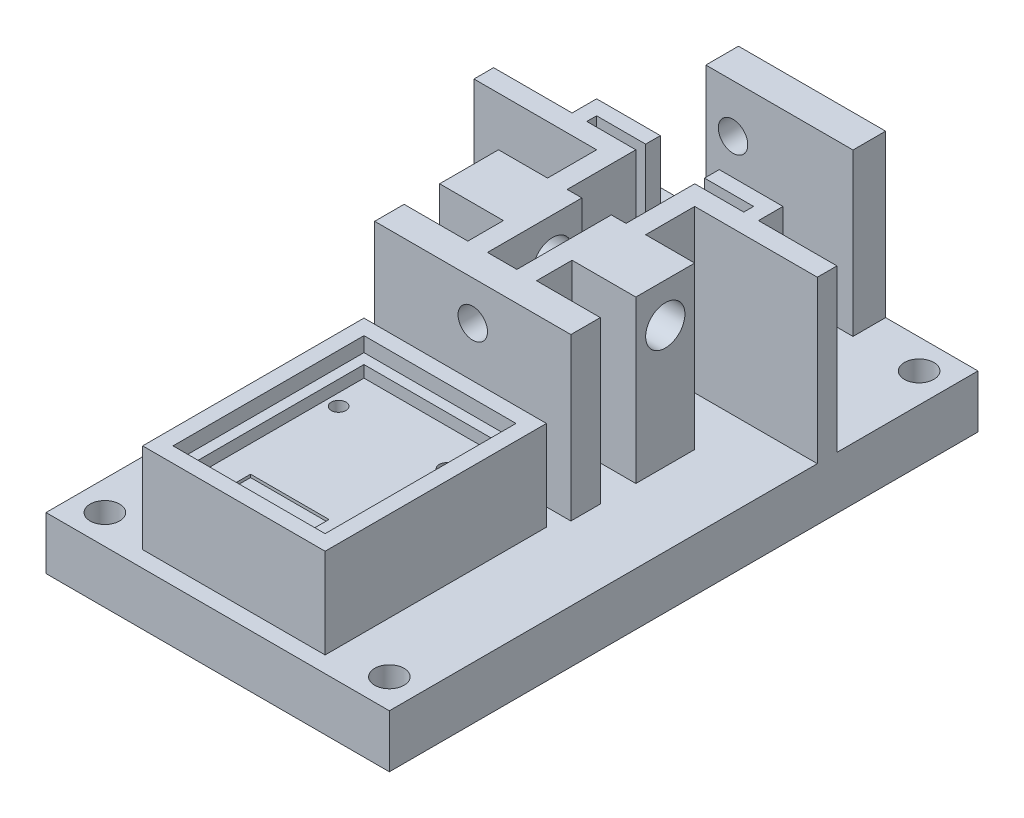
from build123d import *

# Parameters (mm, degrees)
SKETCH1_W                      = 35
SKETCH1_H                      = 60
FLATBASE_DEPTH                 = 5.39
SKETCH19_R                     = 1.5
FLATBASEHOLES_DEPTH            = 6.39
SKETCH2_W                      = 20
SKETCH2_H                      = 3
FILAMENT_LASER_INTERFACE_DEPTH = 16.46
SKETCH4_R                      = 1.5
LASERHOLE_DEPTH                = 3
SKETCH8_W                      = 18.6
SKETCH8_H                      = 22.56
LASER_BASE_DEPTH               = 7.66
SKETCH9_W                      = 13.4
SKETCH9_H                      = 17.36
LASERBOARDMAINCUT_DEPTH        = 1.2
SKETCH11_W                     = 8
SKETCH11_H                     = 4
LASERBOARD_PINHPLES_DEPTH      = 1.5
SKETCH13_W                     = 18.6
SKETCH13_H                     = 22.56
SKETCH13_W_2                   = 15.5
SKETCH13_H_2                   = 19.46
LASERBOARD_SKIRTING_DEPTH      = 1.5
SKETCH14_R                     = 0.75
LASERBOARD_SCREWHOLES_DEPTH    = 12.85
SKETCH20_W                     = 20
SKETCH20_H                     = 6
BOSS_EXTRUDE1_DEPTH            = 16.46
SKETCH22_R                     = 1.115
CUT_EXTRUDE1_DEPTH             = 20
SKETCH23_W                     = 3
SKETCH23_H                     = 6
CUT_EXTRUDE2_DEPTH             = 10
SKETCH24_R                     = 2
CUT_EXTRUDE3_DEPTH             = 4
SKETCH25_R                     = 2
CUT_EXTRUDE4_DEPTH             = 4
SKETCH26_W                     = 2
SKETCH26_H                     = 3.623584384
BOSS_EXTRUDE2_DEPTH            = 16.46
SKETCH27_W                     = 15
SKETCH27_H                     = 3.326415616
BOSS_EXTRUDE3_DEPTH            = 16.46
SKETCH28_R                     = 1.5
CUT_EXTRUDE5_DEPTH             = 3.326416
BOSS_EXTRUDE4_DEPTH            = 16.46


with BuildPart() as part:
    # Sketch1 → FlatBase (new body)
    with BuildSketch(Plane(origin=(0, 0, 0), x_dir=(1, 0, 0), z_dir=(0, 1, 0))):
        Rectangle(SKETCH1_W, SKETCH1_H)
    extrude(amount=FLATBASE_DEPTH)

    # Sketch19 → FlatBaseHoles (cut, through all)
    with BuildSketch(Plane(origin=(0, 5.39, 0), x_dir=(1, 0, 0), z_dir=(0, 1, 0))):
        with Locations((-14.5, 27)):
            Circle(SKETCH19_R)
        with Locations((14.5, 27)):
            Circle(SKETCH19_R)
        with Locations((14.5, -27)):
            Circle(SKETCH19_R)
        with Locations((-14.5, -27)):
            Circle(SKETCH19_R)
    extrude(amount=-FLATBASEHOLES_DEPTH, mode=Mode.SUBTRACT)

    # Sketch2 → Filament-Laser-Interface (add)
    with BuildSketch(Plane(origin=(0, 5.39, 0), x_dir=(1, 0, 0), z_dir=(0, 1, 0))):
        with Locations((0, -2.5)):
            Rectangle(SKETCH2_W, SKETCH2_H)
    extrude(amount=FILAMENT_LASER_INTERFACE_DEPTH)

    # Sketch4 → LaserHole (cut)
    with BuildSketch(Plane(origin=(0, 0, 1), x_dir=(-1, 0, 0), z_dir=(0, 0, -1))):
        with Locations((0, 17.85)):
            Circle(SKETCH4_R)
    extrude(amount=-LASERHOLE_DEPTH, mode=Mode.SUBTRACT)

    # Sketch8 → Laser-Base (add)
    with BuildSketch(Plane(origin=(0, 5.39, 0), x_dir=(1, 0, 0), z_dir=(0, 1, 0))):
        with Locations((0, -17.07)):
            Rectangle(SKETCH8_W, SKETCH8_H)
    extrude(amount=LASER_BASE_DEPTH)

    # Sketch9 → LaserBoardMainCut (cut)
    with BuildSketch(Plane(origin=(0, 13.05, 0), x_dir=(1, 0, 0), z_dir=(0, 1, 0))):
        with Locations((0, -17.07)):
            Rectangle(SKETCH9_W, SKETCH9_H)
    extrude(amount=-LASERBOARDMAINCUT_DEPTH, mode=Mode.SUBTRACT)

    # Sketch11 → LaserBoard-PinHples (cut)
    with BuildSketch(Plane(origin=(0, 13.05, 0), x_dir=(1, 0, 0), z_dir=(0, 1, 0))):
        with Locations((0, -24.65)):
            Rectangle(SKETCH11_W, SKETCH11_H)
    extrude(amount=-LASERBOARD_PINHPLES_DEPTH, mode=Mode.SUBTRACT)

    # Sketch13 → LaserBoard-Skirting (add)
    with BuildSketch(Plane(origin=(0, 13.05, 0), x_dir=(1, 0, 0), z_dir=(0, 1, 0))):
        with Locations((0, -17.07)):
            Rectangle(SKETCH13_W, SKETCH13_H)
        with Locations((0, -17.07)):
            Rectangle(SKETCH13_W_2, SKETCH13_H_2, mode=Mode.SUBTRACT)
    extrude(amount=LASERBOARD_SKIRTING_DEPTH)

    # Sketch14 → LaserBoard-ScrewHoles (cut, through all)
    with BuildSketch(Plane(origin=(0, 11.85, 0), x_dir=(1, 0, 0), z_dir=(0, 1, 0))):
        with Locations((5.5, -12.17)):
            Circle(SKETCH14_R)
        with Locations((-5.5, -12.17)):
            Circle(SKETCH14_R)
    extrude(amount=-LASERBOARD_SCREWHOLES_DEPTH, mode=Mode.SUBTRACT)

    # Sketch20 → Boss-Extrude1 (add)
    with BuildSketch(Plane(origin=(0, 5.39, 0), x_dir=(1, 0, 0), z_dir=(0, 1, 0))):
        with Locations((0, 5.623584384)):
            Rectangle(SKETCH20_W, SKETCH20_H)
    extrude(amount=BOSS_EXTRUDE1_DEPTH)

    # Sketch22 → Cut-Extrude1 (cut)
    with BuildSketch(Plane(origin=(10, 0, 0), x_dir=(0, 0, -1), z_dir=(1, 0, 0))):
        with Locations((5.623584384, 17.85)):
            Circle(SKETCH22_R)
    extrude(amount=-CUT_EXTRUDE1_DEPTH, mode=Mode.SUBTRACT)

    # Sketch23 → Cut-Extrude2 (cut)
    with BuildSketch(Plane(origin=(0, 21.85, 0), x_dir=(1, 0, 0), z_dir=(0, 1, 0))):
        with Locations((0, 5.623584384)):
            Rectangle(SKETCH23_W, SKETCH23_H)
    extrude(amount=-CUT_EXTRUDE2_DEPTH, mode=Mode.SUBTRACT)

    # Sketch24 → Cut-Extrude3 (cut)
    with BuildSketch(Plane(origin=(10, 0, 0), x_dir=(0, 0, -1), z_dir=(1, 0, 0))):
        with Locations((5.623584384, 17.85)):
            Circle(SKETCH24_R)
    extrude(amount=-CUT_EXTRUDE3_DEPTH, mode=Mode.SUBTRACT)

    # Sketch25 → Cut-Extrude4 (cut)
    with BuildSketch(Plane(origin=(-1.5, 0, 0), x_dir=(0, 0, -1), z_dir=(1, 0, 0))):
        with Locations((5.623584384, 17.85)):
            Circle(SKETCH25_R)
    extrude(amount=-CUT_EXTRUDE4_DEPTH, mode=Mode.SUBTRACT)

    # Sketch26 → Boss-Extrude2 (add)
    with BuildSketch(Plane(origin=(0, 5.39, 0), x_dir=(1, 0, 0), z_dir=(0, 1, 0))):
        with Locations((2.5, 0.811792192)):
            Rectangle(SKETCH26_W, SKETCH26_H)
        with Locations((-2.5, 0.811792192)):
            Rectangle(SKETCH26_W, SKETCH26_H)
    extrude(amount=BOSS_EXTRUDE2_DEPTH)

    # Sketch27 → Boss-Extrude3 (add)
    with BuildSketch(Plane(origin=(0, 5.39, 0), x_dir=(1, 0, 0), z_dir=(0, 1, 0))):
        with Locations((0.585, 28.336792192)):
            Rectangle(SKETCH27_W, SKETCH27_H)
    extrude(amount=BOSS_EXTRUDE3_DEPTH)

    # Sketch28 → Cut-Extrude5 (cut)
    with BuildSketch(Plane.XY.offset(-26.673584384)):
        with Locations((-4.145, 8.195)):
            Circle(SKETCH28_R)
        with Locations((-4.145, 16.945)):
            Circle(SKETCH28_R)
    extrude(amount=-CUT_EXTRUDE5_DEPTH, mode=Mode.SUBTRACT)

    # Sketch29 → Boss-Extrude4 (add)
    with BuildSketch(Plane(origin=(0, 5.39, 0), x_dir=(1, 0, 0), z_dir=(0, 1, 0))):
        Polygon((-17.5, 15.623584384), (-9.5, 15.623584384), (-9.5, 18.123584384), (-3, 18.123584384), (-3, 16.623584384), (-8, 16.623584384), (-8, 15.623584384), (-3, 15.623584384), (-3, 13.623584384), (-3, 8.623584384), (-5, 8.623584384), (-5, 13.623584384), (-17.5, 13.623584384), align=None)
        Polygon((17.5, 15.623584384), (17.5, 13.623584384), (5, 13.623584384), (5, 8.623584384), (3, 8.623584384), (3, 13.623584384), (3, 15.623584384), (8, 15.623584384), (8, 16.623584384), (3, 16.623584384), (3, 18.123584384), (9.5, 18.123584384), (9.5, 15.623584384), align=None)
    extrude(amount=BOSS_EXTRUDE4_DEPTH)


solid = part.part
